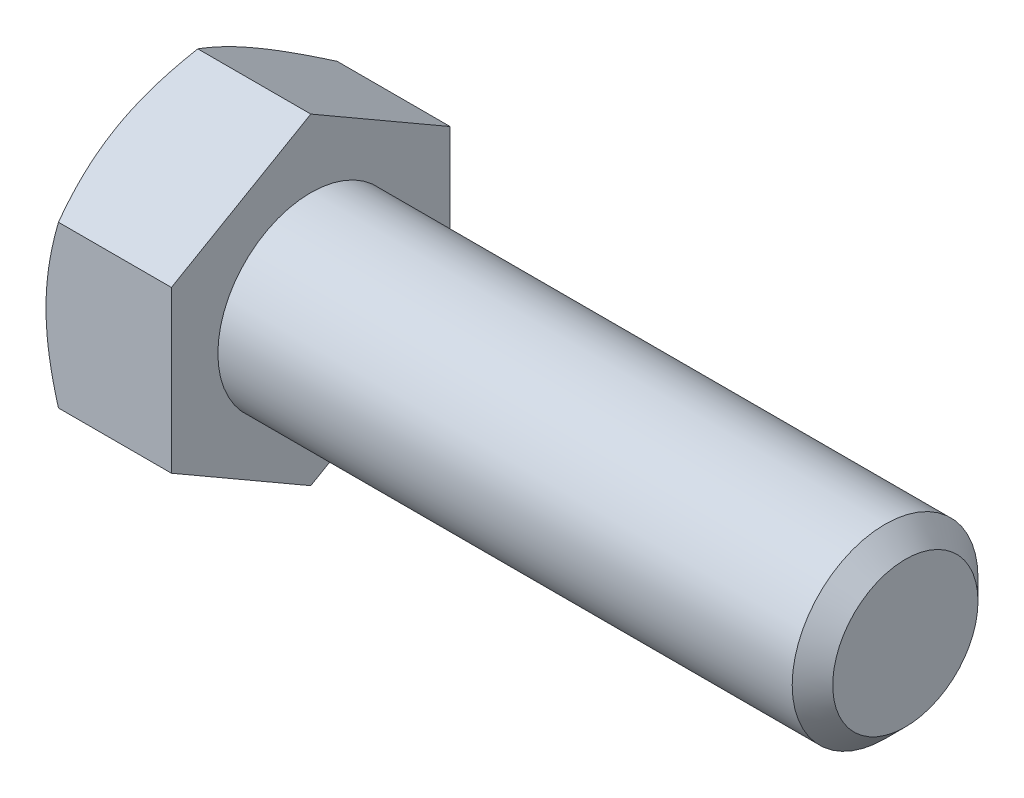
from build123d import *

# Parameters (mm, degrees)
SKETCH5_R           = 7.9375
BOSS_EXTRUDE3_DEPTH = 50.8
CHAMFER1_SIZE       = 1.731818182
BOSS_EXTRUDE4_DEPTH = 10.715625
SKETCH8_OUTSIDE_W   = 256.666
SKETCH8_OUTSIDE_H   = 260.35
SKETCH8_OUTSIDE_R   = 11.90625
CUT_EXTRUDE3_DEPTH  = 62.515625
CUT_EXTRUDE3_TAPER  = 60
CUT_EXTRUDE4_DEPTH  = 0.254
CIRPATTERN1_COUNT   = 6


with BuildPart() as part:
    # Sketch5 → Boss-Extrude3 (new body)
    with BuildSketch(Plane(origin=(30.7578125, 0, 0), x_dir=(0, 0, -1), z_dir=(1, 0, 0))):
        Circle(SKETCH5_R)
    extrude(amount=-BOSS_EXTRUDE3_DEPTH)

    # Chamfer1
    chamfer1_edges = [part.edges().sort_by_distance(p)[0] for p in [
        (30.7578125, 0, 7.9375),
    ]]
    chamfer(chamfer1_edges, length=CHAMFER1_SIZE)

    # Sketch6 → Boss-Extrude4 (add)
    with BuildSketch(Plane.ZY.offset(20.0421875)):
        Polygon((11.90625, 6.874076643), (0, 13.748153285), (-11.90625, 6.874076643), (-11.90625, -6.874076643), (0, -13.748153285), (11.90625, -6.874076643), align=None)
    extrude(amount=BOSS_EXTRUDE4_DEPTH)

    # Sketch8 outside → Cut-Extrude3 (cut, through all)
    with BuildSketch(Plane.ZY.offset(30.7578125)):
        Rectangle(SKETCH8_OUTSIDE_W, SKETCH8_OUTSIDE_H)
        Circle(SKETCH8_OUTSIDE_R, mode=Mode.SUBTRACT)
    extrude(amount=-CUT_EXTRUDE3_DEPTH, taper=CUT_EXTRUDE3_TAPER, mode=Mode.SUBTRACT)

    # Sketch12 → Cut-Extrude4 (cut)
    with BuildSketch(Plane.ZY.offset(30.7578125)):
        with BuildLine():
            Line((0.3571875, 9.1678125), (0.3571875, 5.1196875))
            ThreePointArc((0.3571875, 5.1196875), (0, 4.7625), (-0.3571875, 5.1196875))
            Line((-0.3571875, 5.1196875), (-0.3571875, 9.1678125))
            ThreePointArc((-0.3571875, 9.1678125), (0, 9.525), (0.3571875, 9.1678125))
        make_face()
    cut_extrude4 = extrude(amount=-CUT_EXTRUDE4_DEPTH, mode=Mode.SUBTRACT)

    # CirPattern1: Cut-Extrude4 ×6 about axis
    cirpattern1_axis = Axis((0, 0, 0), (1, 0, 0))
    for i in range(1, CIRPATTERN1_COUNT):
        add(cut_extrude4.rotate(cirpattern1_axis, i * 360 / CIRPATTERN1_COUNT), mode=Mode.SUBTRACT)


solid = part.part
